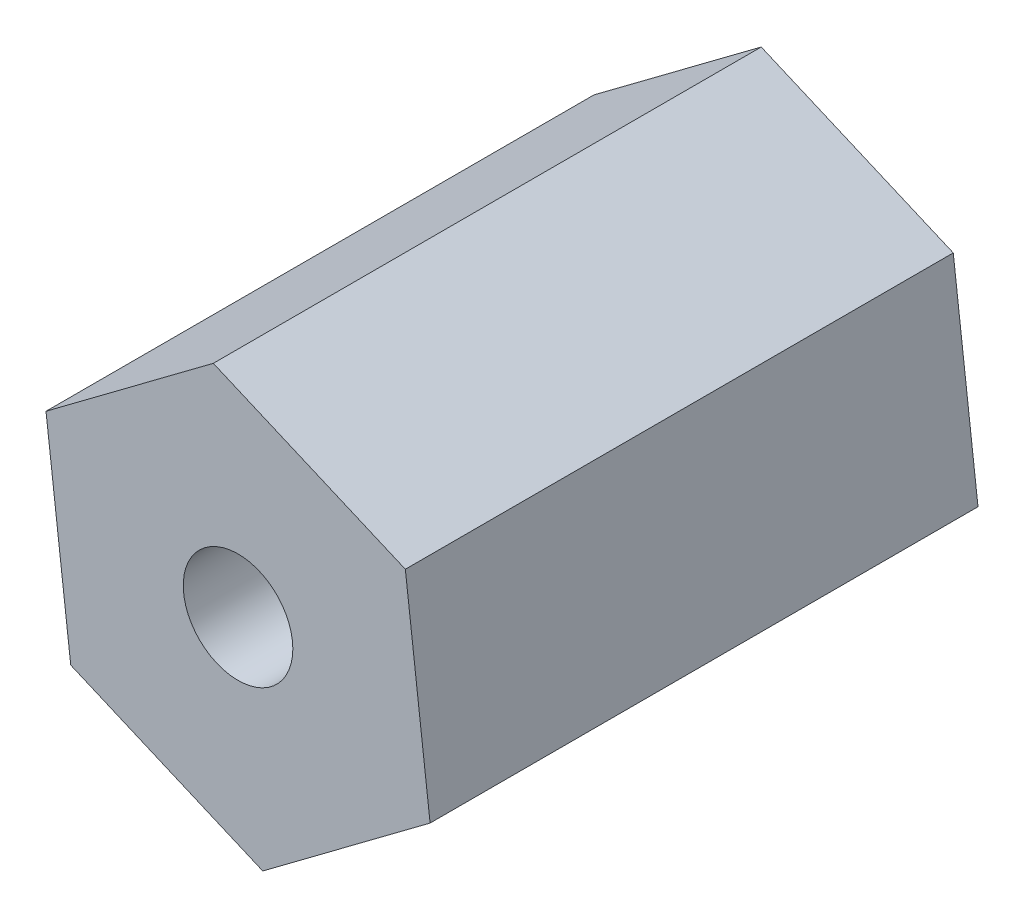
from build123d import *

# Parameters (mm, degrees)
SKETCH7_R           = 0.9525
BOSS_EXTRUDE4_DEPTH = 9.525


with BuildPart() as part:
    # Sketch7 → Boss-Extrude4 (new body)
    with BuildSketch(Plane.XY):
        Polygon((-76.381396916, 4.713520867), (-76.811552533, 8.320159605), (-80.150071111, 9.750953281), (-83.058434072, 7.57510822), (-82.628278454, 3.968469482), (-79.289759876, 2.537675806), align=None)
        with Locations((-79.719915494, 6.144314544)):
            Circle(SKETCH7_R, mode=Mode.SUBTRACT)
    extrude(amount=BOSS_EXTRUDE4_DEPTH)


solid = part.part
